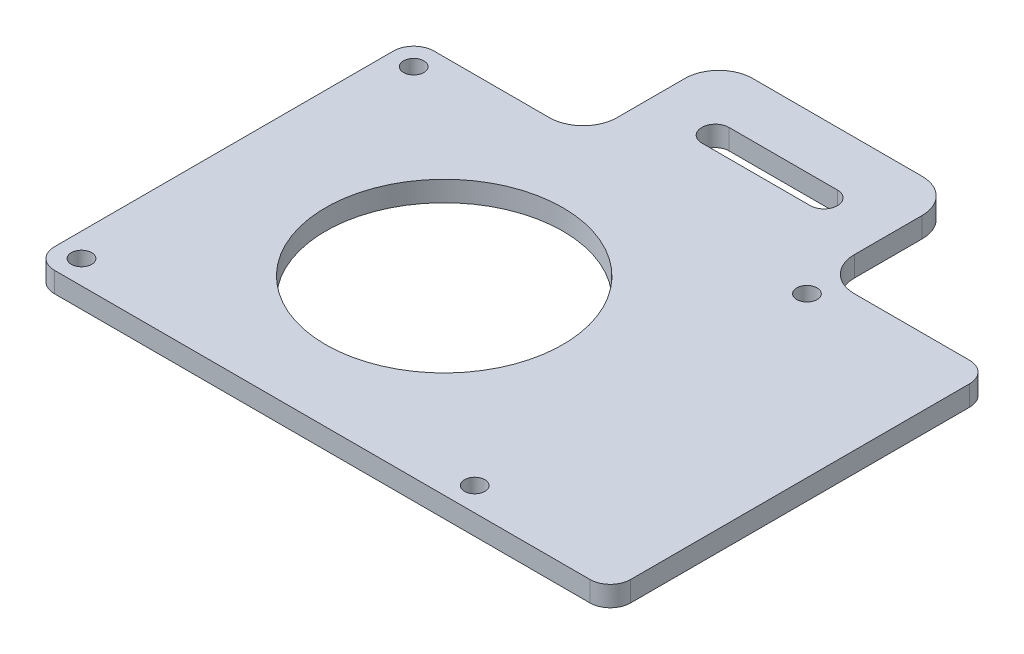
from build123d import *

# Parameters (mm, degrees)
SKETCH1_W               = 85
SKETCH1_H               = 56
BOSS_EXTRUDE1_DEPTH     = 3
SKETCH2_R               = 1.5
CUT_EXTRUDE1_DEPTH      = 1
CUT_EXTRUDE1_DEPTH_BACK = 4
FILLET1_R               = 3
SKETCH3_R               = 17.5
CUT_EXTRUDE2_DEPTH      = 1
CUT_EXTRUDE2_DEPTH_BACK = 4
SKETCH4_W               = 35
SKETCH4_H               = 20
BOSS_EXTRUDE2_DEPTH     = 3
FILLET2_R               = 5
CUT_EXTRUDE3_DEPTH      = 1
CUT_EXTRUDE3_DEPTH_BACK = 4


with BuildPart() as part:
    # Sketch1 → Boss-Extrude1 (new body)
    with BuildSketch(Plane(origin=(0, 0, 0), x_dir=(1, 0, 0), z_dir=(0, 1, 0))):
        Rectangle(SKETCH1_W, SKETCH1_H)
    extrude(amount=BOSS_EXTRUDE1_DEPTH)

    # Sketch2 → Cut-Extrude1 (cut, two sides)
    with BuildSketch(Plane(origin=(0, 3, 0), x_dir=(1, 0, 0), z_dir=(0, 1, 0))) as cut_extrude1_sk:
        with Locations((-39, 24.5)):
            Circle(SKETCH2_R)
        with Locations((19, 24.5)):
            Circle(SKETCH2_R)
        with Locations((19, -24.5)):
            Circle(SKETCH2_R)
        with Locations((-39, -24.5)):
            Circle(SKETCH2_R)
    extrude(amount=CUT_EXTRUDE1_DEPTH, mode=Mode.SUBTRACT)
    extrude(cut_extrude1_sk.sketch, amount=-CUT_EXTRUDE1_DEPTH_BACK, mode=Mode.SUBTRACT)

    # Fillet1
    fillet1_edges = [part.edges().sort_by_distance(p)[0] for p in [
        (42.5, 1.5, 28),
        (-42.5, 1.5, 28),
        (-42.5, 1.5, -28),
        (42.5, 1.5, -28),
    ]]
    fillet(fillet1_edges, radius=FILLET1_R)

    # Sketch3 → Cut-Extrude2 (cut, two sides)
    with BuildSketch(Plane(origin=(0, 3, 0), x_dir=(1, 0, 0), z_dir=(0, 1, 0))) as cut_extrude2_sk:
        with Locations((-10, 0)):
            Circle(SKETCH3_R)
    extrude(amount=CUT_EXTRUDE2_DEPTH, mode=Mode.SUBTRACT)
    extrude(cut_extrude2_sk.sketch, amount=-CUT_EXTRUDE2_DEPTH_BACK, mode=Mode.SUBTRACT)

    # Sketch4 → Boss-Extrude2 (add)
    with BuildSketch(Plane(origin=(0, 3, 0), x_dir=(1, 0, 0), z_dir=(0, 1, 0))):
        with Locations((0, 38)):
            Rectangle(SKETCH4_W, SKETCH4_H)
    extrude(amount=-BOSS_EXTRUDE2_DEPTH)

    # Fillet2
    fillet2_edges = [part.edges().sort_by_distance(p)[0] for p in [
        (17.5, 1.5, -48),
        (17.5, 1.5, -28),
        (-17.5, 1.5, -28),
        (-17.5, 1.5, -48),
    ]]
    fillet(fillet2_edges, radius=FILLET2_R)

    # Sketch5 → Cut-Extrude3 (cut, two sides)
    with BuildSketch(Plane(origin=(0, 3, 0), x_dir=(1, 0, 0), z_dir=(0, 1, 0))) as cut_extrude3_sk:
        with BuildLine():
            Line((-8, 40), (8, 40))
            ThreePointArc((8, 40), (10, 38), (8, 36))
            Line((8, 36), (-8, 36))
            ThreePointArc((-8, 36), (-10, 38), (-8, 40))
        make_face()
    extrude(amount=CUT_EXTRUDE3_DEPTH, mode=Mode.SUBTRACT)
    extrude(cut_extrude3_sk.sketch, amount=-CUT_EXTRUDE3_DEPTH_BACK, mode=Mode.SUBTRACT)


solid = part.part
